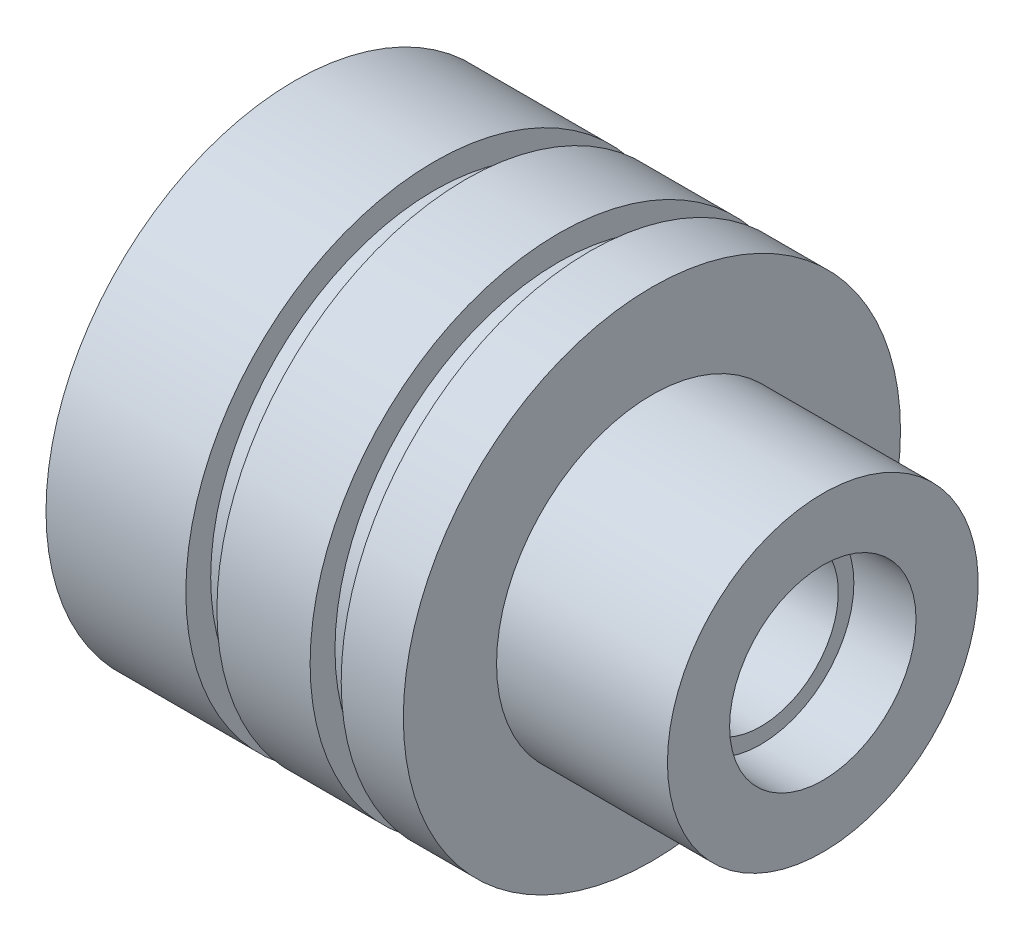
from build123d import *


with BuildPart() as part:
    # Skizze1 → Rotation1 (revolve)
    with BuildSketch(Plane.XY):
        Polygon((0, 8), (0, 2.5), (15, 2.5), (15, 3), (17, 3), (17, 5), (11.5, 5), (11.5, 8), (9.5, 8), (9.5, 7.2), (8.5, 7.2), (8.5, 8), (5.5, 8), (5.5, 7.2), (4.5, 7.2), (4.5, 8), align=None)
    revolve(axis=Axis((0, 0, 0), (1, 0, 0)))


solid = part.part
